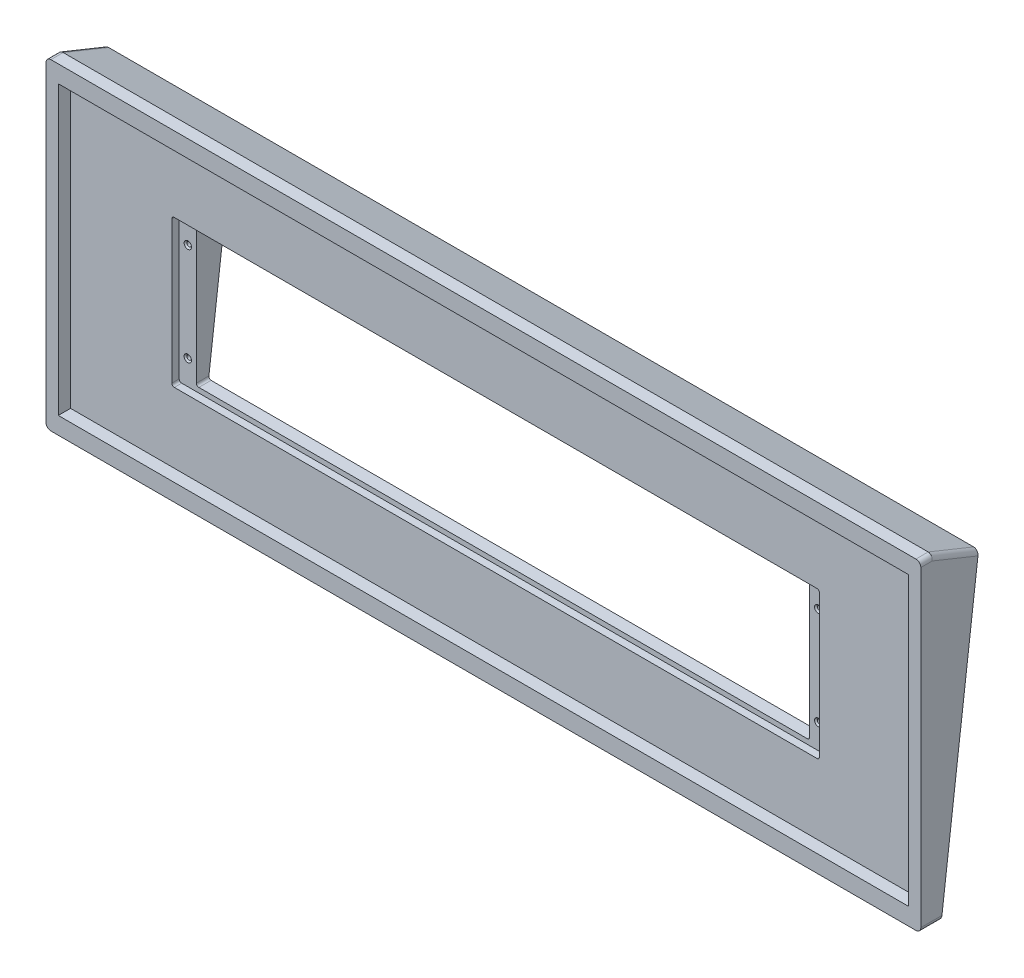
from build123d import *

# Parameters (mm, degrees)
SKETCH3_W                                         = 356.6125
SKETCH3_H                                         = 131.1125
BOSS_EXTRUDE1_DEPTH                               = 5
BOSS_EXTRUDE2_DEPTH                               = 356.6125
SKETCH5_W                                         = 346.6125
SKETCH5_H                                         = 117.1125
CUT_EXTRUDE1_DEPTH                                = 5
SKETCH6_W                                         = 264
SKETCH6_H                                         = 60
CUT_EXTRUDE2_DEPTH                                = 3
SKETCH7_W                                         = 250
SKETCH7_H                                         = 56
CUT_EXTRUDE3_DEPTH                                = 43
FILLET1_R                                         = 1
CSK_FOR_0_FLAT_HEAD_MACHINE_SCREW_100_D           = 1.778
CSK_FOR_0_FLAT_HEAD_MACHINE_SCREW_100_DEPTH       = 5
CSK_FOR_0_FLAT_HEAD_MACHINE_SCREW_100_CSINK_D     = 3.0226
CSK_FOR_0_FLAT_HEAD_MACHINE_SCREW_100_CSINK_ANGLE = 100
CSK_FOR_0_FLAT_HEAD_MACHINE_SCREW_100_TIP         = 0.53416509
CSK_FOR_0_FLAT_HEAD_MACHINE_SCREW_2_D             = 1.778
CSK_FOR_0_FLAT_HEAD_MACHINE_SCREW_2_DEPTH         = 5
CSK_FOR_0_FLAT_HEAD_MACHINE_SCREW_2_CSINK_D       = 3.0226
CSK_FOR_0_FLAT_HEAD_MACHINE_SCREW_2_CSINK_ANGLE   = 100
CSK_FOR_0_FLAT_HEAD_MACHINE_SCREW_2_TIP           = 0.53416509
FILLET2_R                                         = 2


with BuildPart() as part:
    # Sketch3 → Boss-Extrude1 (new body)
    with BuildSketch(Plane.XY):
        with Locations((178.80625, 57.983485256)):
            Rectangle(SKETCH3_W, SKETCH3_H)
    extrude(amount=-BOSS_EXTRUDE1_DEPTH)

    # Sketch4 → Boss-Extrude2 (add)
    with BuildSketch(Plane.ZY.offset(-0.5)):
        Polygon((-5, -7.572764744), (-8.365004472, -7.572764744), (-23.543677091, 116.047603388), (-5, 123.539735256), align=None)
    extrude(amount=-BOSS_EXTRUDE2_DEPTH)

    # Sketch5 → Cut-Extrude1 (cut)
    with BuildSketch(Plane.XY):
        with Locations((178.80625, 57.983485256)):
            Rectangle(SKETCH5_W, SKETCH5_H)
    extrude(amount=-CUT_EXTRUDE1_DEPTH, mode=Mode.SUBTRACT)

    # Sketch6 → Cut-Extrude2 (cut)
    with BuildSketch(Plane.XY.offset(-5)):
        with Locations((178.80625, 57.983485256)):
            Rectangle(SKETCH6_W, SKETCH6_H)
    extrude(amount=-CUT_EXTRUDE2_DEPTH, mode=Mode.SUBTRACT)

    # Sketch7 → Cut-Extrude3 (cut)
    with BuildSketch(Plane.XY.offset(-8)):
        with Locations((178.80625, 57.983485256)):
            Rectangle(SKETCH7_W, SKETCH7_H)
    extrude(amount=-CUT_EXTRUDE3_DEPTH, mode=Mode.SUBTRACT)

    # Fillet1
    fillet1_edges = [part.edges().sort_by_distance(p)[0] for p in [
        (46.80625, 27.983485256, -6.5),
        (46.80625, 87.983485256, -6.5),
        (310.80625, 87.983485256, -6.5),
        (310.80625, 27.983485256, -6.5),
        (53.80625, 29.983485256, -10.488166069),
        (53.80625, 85.983485256, -13.926133774),
        (303.80625, 85.983485256, -13.926133774),
        (303.80625, 29.983485256, -10.488166069),
    ]]
    fillet(fillet1_edges, radius=FILLET1_R)

    # CSK for _0 Flat Head Machine Screw _100
    with Locations(Plane.XY.offset(-8)):
        with Locations((50.30625, 77.983485256), (50.30625, 37.983485256)):
            CounterSinkHole(CSK_FOR_0_FLAT_HEAD_MACHINE_SCREW_100_D / 2, CSK_FOR_0_FLAT_HEAD_MACHINE_SCREW_100_CSINK_D / 2, depth=CSK_FOR_0_FLAT_HEAD_MACHINE_SCREW_100_DEPTH, counter_sink_angle=CSK_FOR_0_FLAT_HEAD_MACHINE_SCREW_100_CSINK_ANGLE)
            with Locations((0, 0, -(CSK_FOR_0_FLAT_HEAD_MACHINE_SCREW_100_DEPTH + CSK_FOR_0_FLAT_HEAD_MACHINE_SCREW_100_TIP / 2))):  # 118° drill point
                Cone(0, CSK_FOR_0_FLAT_HEAD_MACHINE_SCREW_100_D / 2, CSK_FOR_0_FLAT_HEAD_MACHINE_SCREW_100_TIP, mode=Mode.SUBTRACT)

    # CSK for _0 Flat Head Machine Screw _ 2
    with Locations(Plane.XY.offset(-8)):
        with Locations((307.30625, 77.983485256), (307.30625, 37.983485256)):
            CounterSinkHole(CSK_FOR_0_FLAT_HEAD_MACHINE_SCREW_2_D / 2, CSK_FOR_0_FLAT_HEAD_MACHINE_SCREW_2_CSINK_D / 2, depth=CSK_FOR_0_FLAT_HEAD_MACHINE_SCREW_2_DEPTH, counter_sink_angle=CSK_FOR_0_FLAT_HEAD_MACHINE_SCREW_2_CSINK_ANGLE)
            with Locations((0, 0, -(CSK_FOR_0_FLAT_HEAD_MACHINE_SCREW_2_DEPTH + CSK_FOR_0_FLAT_HEAD_MACHINE_SCREW_2_TIP / 2))):  # 118° drill point
                Cone(0, CSK_FOR_0_FLAT_HEAD_MACHINE_SCREW_2_D / 2, CSK_FOR_0_FLAT_HEAD_MACHINE_SCREW_2_TIP, mode=Mode.SUBTRACT)

    # Fillet2
    fillet2_edges = [part.edges().sort_by_distance(p)[0] for p in [
        (0.5, 119.793669322, -14.271838546),
        (357.1125, 119.793669322, -14.271838546),
        (357.1125, -7.572764744, -4.182502236),
        (0.5, -7.572764744, -4.182502236),
        (0.5, 123.539735256, -2.5),
        (357.1125, 123.539735256, -2.5),
    ]]
    fillet(fillet2_edges, radius=FILLET2_R)


solid = part.part
